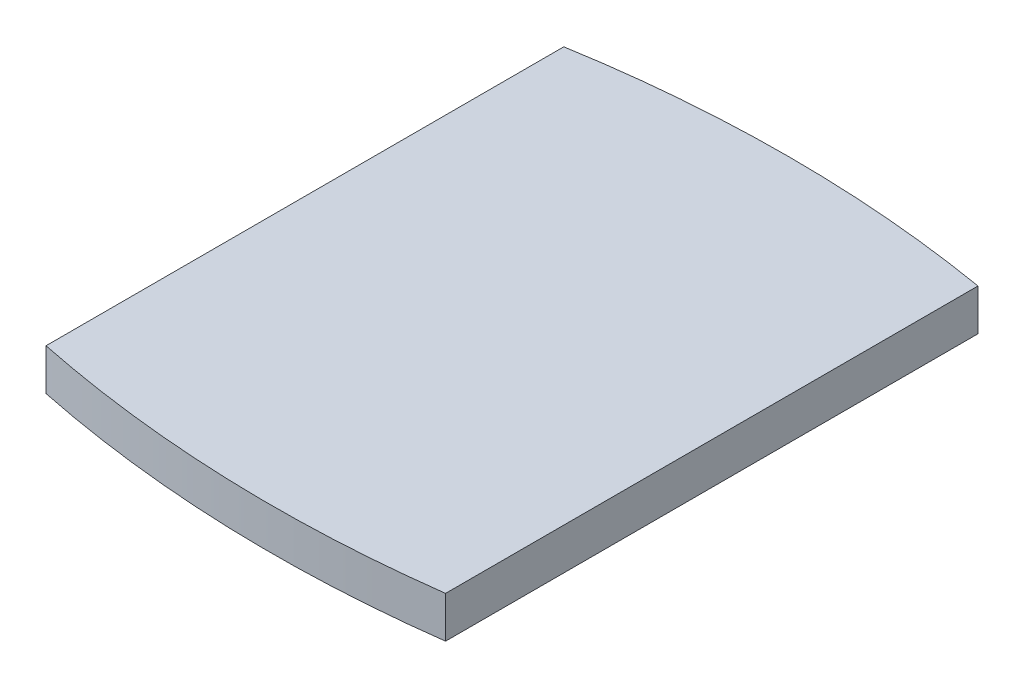
from build123d import *

# Parameters (mm, degrees)
EXTRUDE_1_DEPTH = 2


with BuildPart() as part:
    # Эскиз1 → Бобышка-Вытянуть1 (new body)
    with BuildSketch(Plane(origin=(0, 0, 0), x_dir=(1, 0, 0), z_dir=(0, 1, 0))):
        with BuildLine():
            Line((0, 0), (0, 25))
            ThreePointArc((0, 25), (10, 25.839202169), (20, 25))
            Line((20, 25), (20, -0.706999977))
            ThreePointArc((20, -0.706999977), (9.970315411, -1.19323378), (0, 0))
        make_face()
    extrude(amount=EXTRUDE_1_DEPTH)


solid = part.part
